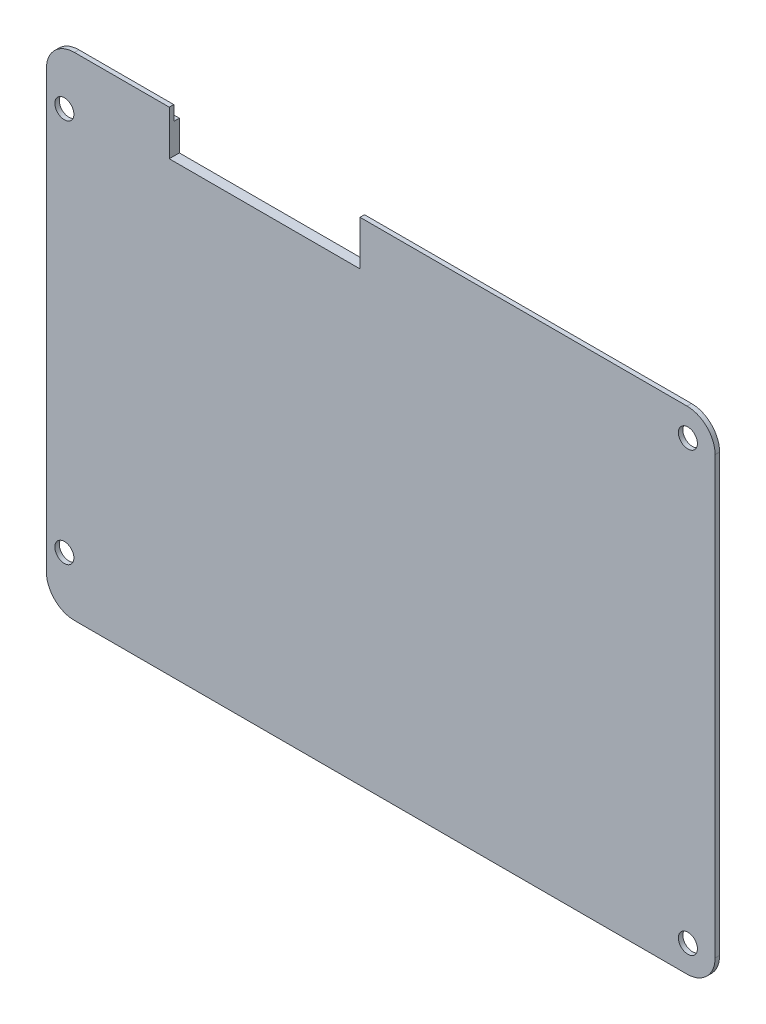
from build123d import *

# Parameters (mm, degrees)
SKIZZE1_R                       = 1.7
AUFSATZ_LINEAR_AUSTRAGEN1_DEPTH = 0.8
AUFSATZ_LINEAR_AUSTRAGEN2_DEPTH = 1


with BuildPart() as part:
    # Skizze1 → Aufsatz-Linear austragen1 (new body)
    with BuildSketch(Plane.XY):
        with BuildLine():
            Line((0, 5), (0, 82.7))
            ThreePointArc((0, 82.7), (1.464466094, 86.235533906), (5, 87.7))
            Line((5, 87.7), (21.9, 87.7))
            Line((21.9, 87.7), (21.9, 79.73388451))
            Line((21.9, 79.73388451), (55.9, 79.73388451))
            Line((55.9, 79.73388451), (55.9, 87.7))
            Line((55.9, 87.7), (114.2, 87.7))
            ThreePointArc((114.2, 87.7), (117.735533906, 86.235533906), (119.2, 82.7))
            Line((119.2, 82.7), (119.2, 75.8))
            Line((119.2, 75.8), (119.2, 5))
            ThreePointArc((119.2, 5), (117.735533906, 1.464466094), (114.2, 0))
            Line((114.2, 0), (5, 0))
            ThreePointArc((5, 0), (1.464466094, 1.464466094), (0, 5))
        make_face()
        with Locations((3.2, 9.6)):
            Circle(SKIZZE1_R, mode=Mode.SUBTRACT)
        with Locations((3.2, 78.1)):
            Circle(SKIZZE1_R, mode=Mode.SUBTRACT)
        with Locations((114.35, 82.85)):
            Circle(SKIZZE1_R, mode=Mode.SUBTRACT)
        with Locations((114.35, 4.85)):
            Circle(SKIZZE1_R, mode=Mode.SUBTRACT)
    extrude(amount=AUFSATZ_LINEAR_AUSTRAGEN1_DEPTH)

    # Skizze3 → Aufsatz-Linear austragen2 (add)
    with BuildSketch(Plane(origin=(0, 0, 0), x_dir=(-1, 0, 0), z_dir=(0, 0, -1))):
        Polygon((-55.9, 79.73388451), (-55.9, 85.1), (-105.458578644, 85.1), (-117.5, 73.058578644), (-117.5, 14.641421356), (-105.458578644, 2.6), (-6.5, 2.6), (-6.5, 17.286335909), (-1.7, 22.086335909), (-1.7, 66.058578644), (-6.5, 70.858578644), (-6.5, 85.1), (-21.9, 85.1), (-21.9, 79.73388451), align=None)
        Polygon((-58.844037441, 83.9), (-57.1, 83.9), (-57.1, 78.53388451), (-20.7, 78.53388451), (-20.7, 83.9), (-7.7, 83.9), (-7.7, 82.43185957), (-58.844037441, 45.143695389), align=None, mode=Mode.SUBTRACT)
        Polygon((-104.961522369, 83.9), (-60.044037441, 83.9), (-60.044037441, 45.139977904), (-108.547677312, 80.313845057), align=None, mode=Mode.SUBTRACT)
        Polygon((-116.3, 72.561522369), (-109.406904246, 79.454618123), (-61.293455008, 44.563709394), (-116.3, 44.563709394), align=None, mode=Mode.SUBTRACT)
        Polygon((-116.3, 15.138477631), (-116.3, 43.363709394), (-61.293455008, 43.363709394), (-109.538727473, 8.377205104), align=None, mode=Mode.SUBTRACT)
        Polygon((-104.961522369, 3.8), (-108.679500539, 7.51797817), (-60.044037441, 42.787440884), (-60.044037441, 3.8), align=None, mode=Mode.SUBTRACT)
        Polygon((-7.5, 3.8), (-58.844037441, 3.8), (-58.844037441, 42.7837234), (-7.5, 5.349742948), align=None, mode=Mode.SUBTRACT)
        Polygon((-7.5, 17.983392184), (-7.5, 6.834817309), (-57.602628153, 43.363709394), (-2.9, 43.363709394), (-2.9, 22.583392184), align=None, mode=Mode.SUBTRACT)
        Polygon((-2.9, 65.561522369), (-2.9, 44.563709394), (-57.602628153, 44.563709394), (-7.7, 80.946785208), (-7.7, 70.361522369), align=None, mode=Mode.SUBTRACT)
    extrude(amount=AUFSATZ_LINEAR_AUSTRAGEN2_DEPTH)


solid = part.part
